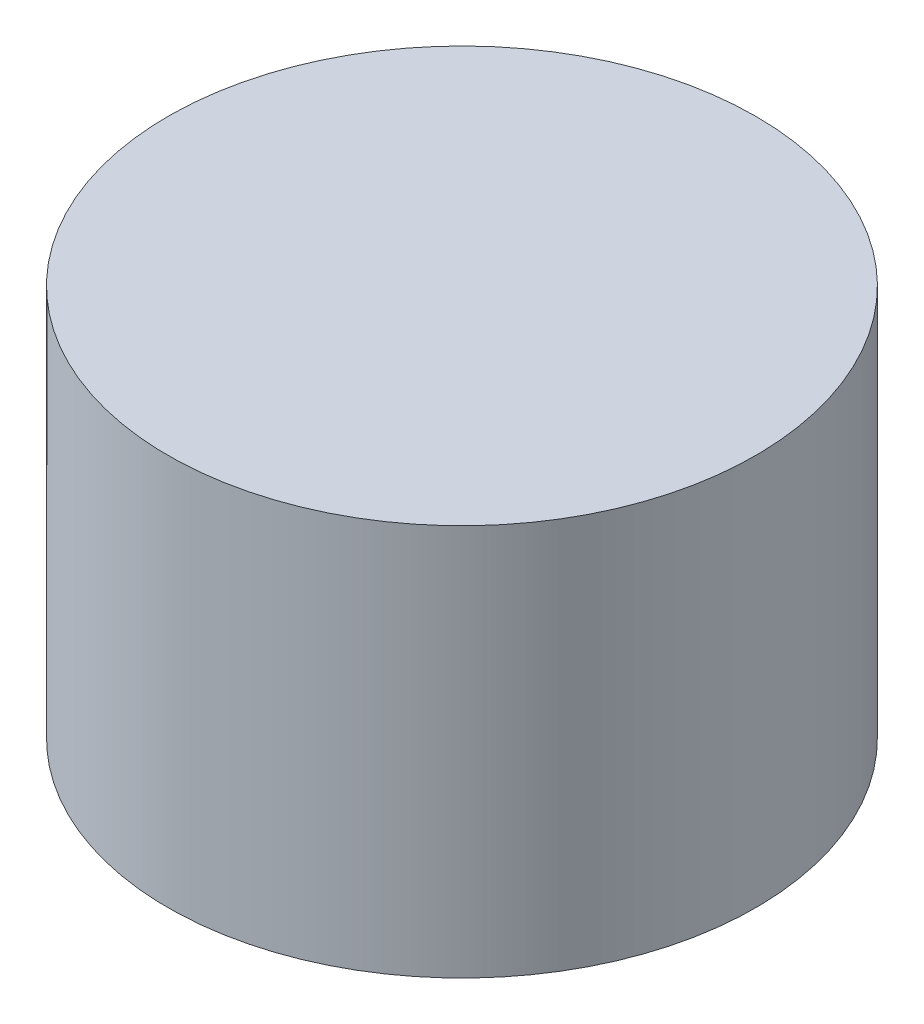
from build123d import *

# Parameters (mm, degrees)
ESBO_O1_W = 150
ESBO_O1_H = 200


with BuildPart() as part:
    # Esboço1 → Revolução1 (revolve)
    with BuildSketch(Plane.XY):
        with Locations((75, 100)):
            Rectangle(ESBO_O1_W, ESBO_O1_H)
    revolve(axis=Axis((0, 0, 0), (0, 1, 0)))


solid = part.part
